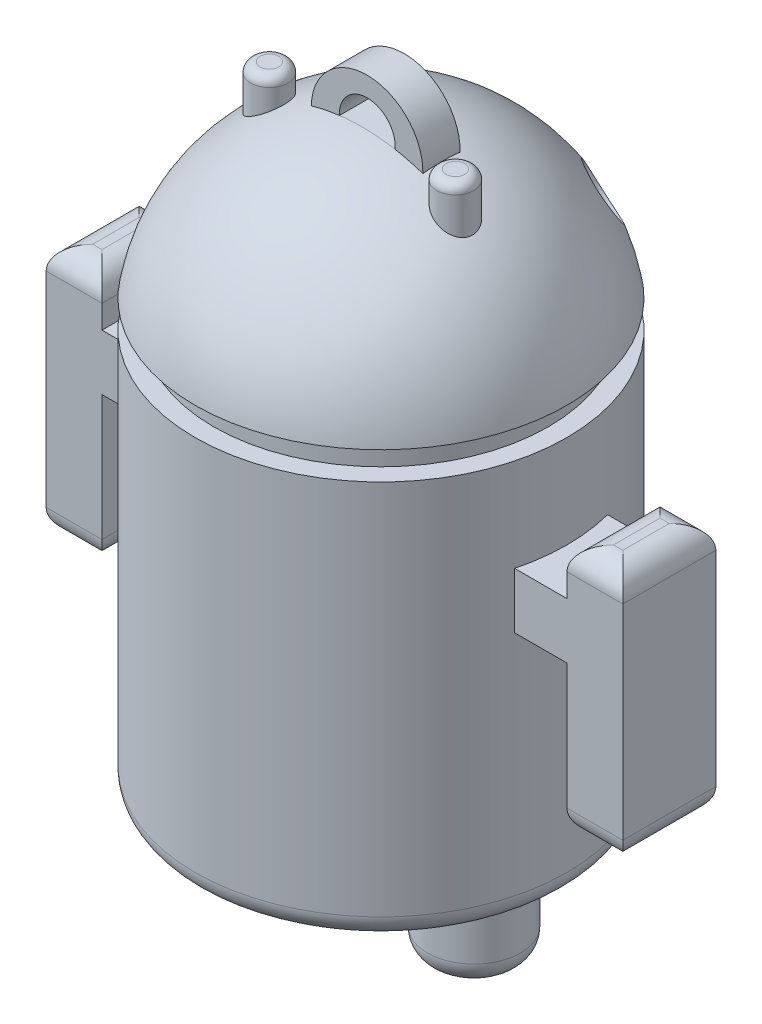
from build123d import *

# Parameters (mm, degrees)
CROQUIS2_R               = 3
CORTAR_EXTRUIR1_DEPTH    = 21
CROQUIS9_R               = 2
SALIENTE_EXTRUIR4_DEPTH  = 64
CROQUIS12_R              = 5
SALIENTE_EXTRUIR7_DEPTH  = 10
SALIENTE_EXTRUIR8_DEPTH  = 5
CROQUIS18_R              = 6
SALIENTE_EXTRUIR10_DEPTH = 2
CORTAR_EXTRUIR7_DEPTH    = 4
REDONDEO7_R              = 1
REDONDEO8_R              = 2.5
REDONDEO9_R              = 2.5
REDONDEO10_R             = 2.5
REDONDEO13_R             = 2.5


with BuildPart() as part:
    # Croquis1 → Revolución1 (revolve)
    with BuildSketch(Plane.XY):
        with BuildLine():
            Line((0, 63), (0, 0))
            Line((0, 0), (20, 0))
            Line((20, 0), (20, 43))
            Line((20, 43), (18, 43))
            Line((18, 43), (18, 46))
            Line((18, 46), (20, 46))
            ThreePointArc((20, 46), (13.124404748, 58.175770292), (0, 63))
        make_face()
    revolve(axis=Axis((0, 63, 0), (0, -1, 0)))

    # Croquis2 → Cortar-Extruir1 (cut, through all)
    with BuildSketch(Plane.XY):
        with Locations((-8, 52)):
            Circle(CROQUIS2_R)
        with Locations((8, 52)):
            Circle(CROQUIS2_R)
    extrude(amount=-CORTAR_EXTRUIR1_DEPTH, mode=Mode.SUBTRACT)

    # Croquis9 → Saliente-Extruir4 (add)
    with BuildSketch(Plane(origin=(0, 0, 0), x_dir=(1, 0, 0), z_dir=(0, 1, 0))):
        with Locations((-10, -2)):
            Circle(CROQUIS9_R)
    saliente_extruir4 = extrude(amount=SALIENTE_EXTRUIR4_DEPTH)

    # Croquis12 → Saliente-Extruir7 (add)
    with BuildSketch(Plane(origin=(0, 0, 0), x_dir=(1, 0, 0), z_dir=(0, 1, 0))):
        with Locations((-10, 0)):
            Circle(CROQUIS12_R)
    saliente_extruir7 = extrude(amount=-SALIENTE_EXTRUIR7_DEPTH)

    # Croquis17 → Saliente-Extruir8 (add, symmetric)
    with BuildSketch(Plane.XY):
        Polygon((-5, 27), (-25, 27), (-25, 11), (-31, 11), (-31, 38), (-25, 38), (-25, 33), (-5, 33), align=None)
    saliente_extruir8 = extrude(amount=SALIENTE_EXTRUIR8_DEPTH, both=True)

    # Simetría4: Saliente-Extruir4, Saliente-Extruir7, Saliente-Extruir8 across plane
    add(saliente_extruir4.mirror(Plane(origin=(0, 0, 0), x_dir=(0, 0, 1), z_dir=(1, 0, 0))))
    add(saliente_extruir7.mirror(Plane(origin=(0, 0, 0), x_dir=(0, 0, 1), z_dir=(1, 0, 0))))
    add(saliente_extruir8.mirror(Plane(origin=(0, 0, 0), x_dir=(0, 0, 1), z_dir=(1, 0, 0))))

    # Croquis18 → Saliente-Extruir10 (add, symmetric)
    with BuildSketch(Plane.XY):
        with Locations((0.5, 62)):
            Circle(CROQUIS18_R)
    extrude(amount=SALIENTE_EXTRUIR10_DEPTH, both=True)

    # Croquis20 → Cortar-Extruir7 (cut)
    with BuildSketch(Plane(origin=(0, 0, -2), x_dir=(-1, 0, 0), z_dir=(0, 0, -1))):
        with BuildLine():
            ThreePointArc((-3.508102494, 62.593580081), (-0.52321022, 62.894276125), (2.473261535, 62.74882159))
            ThreePointArc((2.473261535, 62.74882159), (-0.601046604, 65.893266204), (-3.508102494, 62.593580081))
        make_face()
    extrude(amount=-CORTAR_EXTRUIR7_DEPTH, mode=Mode.SUBTRACT)

    # Redondeo7
    redondeo7_edges = [part.edges().sort_by_distance(p)[0] for p in [
        (-12, 64, 2),
        (12, 64, 2),
    ]]
    fillet(redondeo7_edges, radius=REDONDEO7_R)

    # Redondeo8
    redondeo8_edges = [part.edges().sort_by_distance(p)[0] for p in [
        (-15, -10, 0),
        (15, -10, 0),
    ]]
    fillet(redondeo8_edges, radius=REDONDEO8_R)

    # Redondeo9
    redondeo9_edges = [part.edges().sort_by_distance(p)[0] for p in [
        (-28, 11, 5),
        (-28, 11, -5),
        (-31, 11, 0),
        (-25, 11, 0),
        (28, 11, -5),
        (31, 11, 0),
        (28, 11, 5),
        (25, 11, 0),
    ]]
    fillet(redondeo9_edges, radius=REDONDEO9_R)

    # Redondeo10
    redondeo10_edges = [part.edges().sort_by_distance(p)[0] for p in [
        (-28, 38, 5),
        (-31, 38, 0),
        (-28, 38, -5),
        (-25, 38, 0),
        (28, 38, -5),
        (28, 38, 5),
        (31, 38, 0),
        (25, 38, 0),
    ]]
    fillet(redondeo10_edges, radius=REDONDEO10_R)

    # Redondeo13
    redondeo13_edges = [part.edges().sort_by_distance(p)[0] for p in [
        (-20, 0, 0),
    ]]
    fillet(redondeo13_edges, radius=REDONDEO13_R)


solid = part.part
